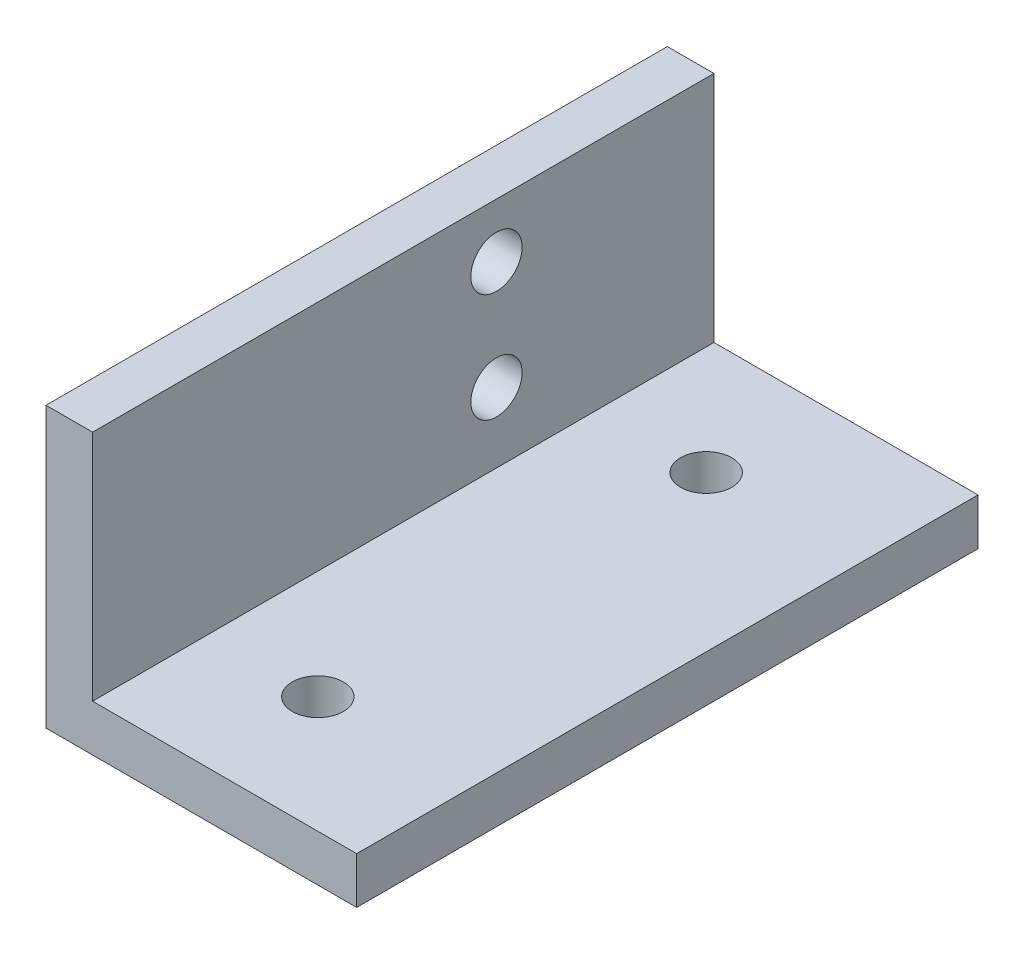
from build123d import *

# Parameters (mm, degrees)
RESSALTO_EXTRUS_O1_DEPTH = 40
ESBO_O2_R                = 1.65
CORTE_EXTRUS_O1_DEPTH    = 40
ESBO_O3_R                = 1.65
CORTE_EXTRUS_O2_DEPTH    = 40


with BuildPart() as part:
    # Esboço1 → Ressalto-extrusão1 (new body)
    with BuildSketch(Plane.XY):
        Polygon((20, 0), (0, 0), (0, 18), (3, 18), (3, 3), (20, 3), align=None)
    extrude(amount=RESSALTO_EXTRUS_O1_DEPTH)

    # Esboço2 → Corte-extrusão1 (cut)
    with BuildSketch(Plane.XZ):
        with Locations((10, 7.5)):
            Circle(ESBO_O2_R)
        with Locations((10, 32.5)):
            Circle(ESBO_O2_R)
    extrude(amount=-CORTE_EXTRUS_O1_DEPTH, mode=Mode.SUBTRACT)

    # Esboço3 → Corte-extrusão2 (cut)
    with BuildSketch(Plane.ZY):
        with Locations((14, 7.5)):
            Circle(ESBO_O3_R)
        with Locations((14, 14.5)):
            Circle(ESBO_O3_R)
    extrude(amount=-CORTE_EXTRUS_O2_DEPTH, mode=Mode.SUBTRACT)


solid = part.part
